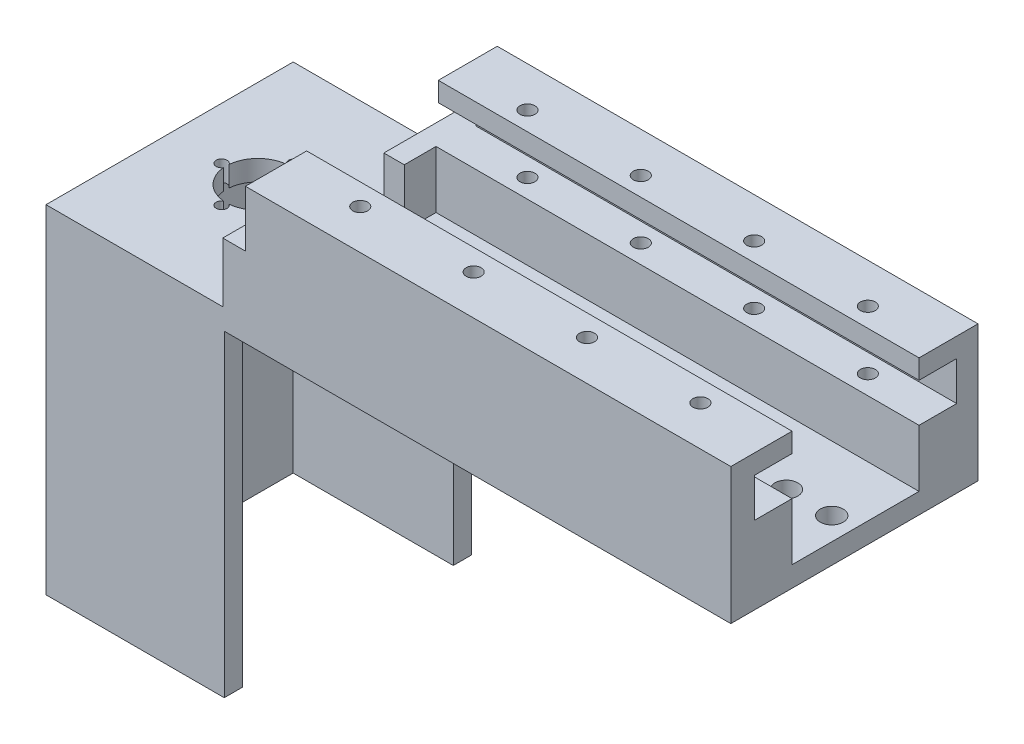
from build123d import *

# Parameters (mm, degrees)
SKETCH4_W                  = 106
SKETCH4_H                  = 30
BOSS_EXTRUDE2_DEPTH        = 13
SKETCH25_W                 = 106
SKETCH25_H                 = 8.6
CUT_EXTRUDE3_DEPTH         = 1
CUT_EXTRUDE3_DEPTH_BACK    = 8.3
M4X0_7_TAPPED_HOLE1_D      = 3.3
SKETCH28_W                 = 106
SKETCH28_H                 = 4.5
BOSS_EXTRUDE3_DEPTH        = 41.5
SKETCH32_W                 = 41.5
SKETCH32_H                 = 4.5
BOSS_EXTRUDE10_DEPTH       = 5
SKETCH33_W                 = 13
SKETCH33_H                 = 17.121445937
BOSS_EXTRUDE12_DEPTH       = 5
SKETCH34_W                 = 4.498886861
SKETCH34_H                 = 12.621445937
BOSS_EXTRUDE13_DEPTH       = 7
SKETCH35_W                 = 54.5
SKETCH35_H                 = 4.5
BOSS_EXTRUDE14_DEPTH       = 40
SKETCH36_W                 = 5
SKETCH36_H                 = 20
BOSS_EXTRUDE15_DEPTH       = 13.12
F_8_0_199_DIAMETER_HOLE1_D = 5.0546
SKETCH39_R                 = 7
CUT_EXTRUDE4_DEPTH         = 10
M2_CLEARANCE_HOLE1_D       = 2.4
SKETCH43_W                 = 35.304815243
SKETCH43_H                 = 4
BOSS_EXTRUDE16_DEPTH       = 70
SKETCH44_W                 = 107.027081708
SKETCH44_H                 = 13.5
BOSS_EXTRUDE17_DEPTH       = 25.5
SKETCH47_W                 = 107.027081708
SKETCH47_H                 = 8.6
CUT_EXTRUDE5_DEPTH         = 8.3
M4X0_7_TAPPED_HOLE2_D      = 3.3


with BuildPart() as part:
    # Sketch4 → Boss-Extrude2 (new body)
    with BuildSketch(Plane.XY):
        with Locations((-36.891047602, -35.322762913)):
            Rectangle(SKETCH4_W, SKETCH4_H)
    extrude(amount=-BOSS_EXTRUDE2_DEPTH)

    # Sketch25 → Cut-Extrude3 (cut, two sides)
    with BuildSketch(Plane.XY) as cut_extrude3_sk:
        with Locations((-36.891047602, -28.901316976)):
            Rectangle(SKETCH25_W, SKETCH25_H)
    extrude(amount=CUT_EXTRUDE3_DEPTH, mode=Mode.SUBTRACT)
    extrude(cut_extrude3_sk.sketch, amount=-CUT_EXTRUDE3_DEPTH_BACK, mode=Mode.SUBTRACT)

    # M4x0.7 Tapped Hole1 (through all)
    with Locations(Plane(origin=(-74.390985602, -20.322762913, -4.15), x_dir=(0, 0, 1), z_dir=(0, 1, 0))):
        with Locations((0, 0), (0, 25), (-0.055677319, 74.999938), (0, 50)):
            Hole(M4X0_7_TAPPED_HOLE1_D / 2)

    # Sketch28 → Boss-Extrude3 (add)
    with BuildSketch(Plane.XY):
        with Locations((-36.891047602, -48.072762913)):
            Rectangle(SKETCH28_W, SKETCH28_H)
    extrude(amount=BOSS_EXTRUDE3_DEPTH)

    # Sketch32 → Boss-Extrude10 (add)
    with BuildSketch(Plane.ZY.offset(89.891047602)):
        with Locations((20.75, -48.072762913)):
            Rectangle(SKETCH32_W, SKETCH32_H)
    extrude(amount=BOSS_EXTRUDE10_DEPTH)

    # Sketch33 → Boss-Extrude12 (add)
    with BuildSketch(Plane.ZY.offset(89.891047602)):
        with Locations((-6.5, -41.762039945)):
            Rectangle(SKETCH33_W, SKETCH33_H)
    extrude(amount=BOSS_EXTRUDE12_DEPTH)

    # Sketch34 → Boss-Extrude13 (add)
    with BuildSketch(Plane.XY):
        with Locations((-92.641604172, -39.512039945)):
            Rectangle(SKETCH34_W, SKETCH34_H)
    extrude(amount=BOSS_EXTRUDE13_DEPTH)

    # Sketch35 → Boss-Extrude14 (add)
    with BuildSketch(Plane.ZY.offset(94.891047602)):
        with Locations((14.25, -48.072762913)):
            Rectangle(SKETCH35_W, SKETCH35_H)
    extrude(amount=BOSS_EXTRUDE14_DEPTH)

    # Sketch36 → Boss-Extrude15 (add)
    with BuildSketch(Plane(origin=(0, -45.822762913, 0), x_dir=(1, 0, 0), z_dir=(0, 1, 0))):
        with Locations((-93.41812931, -31.5)):
            Rectangle(SKETCH36_W, SKETCH36_H)
    extrude(amount=BOSS_EXTRUDE15_DEPTH)

    # #8 (0.199) Diameter Hole1 (through all)
    with Locations(Plane(origin=(-80.669073904, -45.822762913, 14.25), x_dir=(0, 0, 1), z_dir=(0, 1, 0))):
        with Locations((0, 0), (0, 91.778026302), (0, 81.778026302), (0, 10)):
            Hole(F_8_0_199_DIAMETER_HOLE1_D / 2)

    # Sketch39 → Cut-Extrude4 (cut)
    with BuildSketch(Plane(origin=(0, -45.822762913, 0), x_dir=(1, 0, 0), z_dir=(0, 1, 0))):
        with Locations((-115.41812931, -14.25)):
            Circle(SKETCH39_R)
    extrude(amount=-CUT_EXTRUDE4_DEPTH, mode=Mode.SUBTRACT)

    # M2 Clearance Hole1 (through all)
    with Locations(Plane(origin=(-107.41812931, -45.822762913, 14.25), x_dir=(0, 0, 1), z_dir=(0, 1, 0))):
        with Locations((0, 0), (8.000007036, -8.002918292), (-7.999992964, -8.002918292), (0, -16)):
            Hole(M2_CLEARANCE_HOLE1_D / 2)

    # Sketch43 → Boss-Extrude16 (add)
    with BuildSketch(Plane(origin=(0, -50.322762913, 0), x_dir=(-1, 0, 0), z_dir=(0, -1, 0))):
        Polygon((95.586232359, -37.5), (95.586232359, -41.5), (134.891047602, -41.5), (134.891047602, -37.5), (130.891047602, -37.5), align=None)
        Polygon((130.891047602, -37.5), (134.891047602, -37.5), (134.891047602, 13), (130.891047602, 13), (130.891047602, 9), align=None)
        with Locations((113.238639981, 11)):
            Rectangle(SKETCH43_W, SKETCH43_H)
    extrude(amount=BOSS_EXTRUDE16_DEPTH)

    # Sketch44 → Boss-Extrude17 (add)
    with BuildSketch(Plane(origin=(0, -45.822762913, 0), x_dir=(1, 0, 0), z_dir=(0, 1, 0))):
        with Locations((-37.404588456, -34.75)):
            Rectangle(SKETCH44_W, SKETCH44_H)
    extrude(amount=BOSS_EXTRUDE17_DEPTH)

    # Sketch47 → Cut-Extrude5 (cut)
    with BuildSketch(Plane(origin=(0, 0, 28), x_dir=(-1, 0, 0), z_dir=(0, 0, -1))):
        with Locations((37.404588456, -28.902762913)):
            Rectangle(SKETCH47_W, SKETCH47_H)
    extrude(amount=-CUT_EXTRUDE5_DEPTH, mode=Mode.SUBTRACT)

    # M4x0.7 Tapped Hole2 (through all)
    with Locations(Plane(origin=(-74.391047602, -20.322762913, 32.71), x_dir=(0, 0, 1), z_dir=(0, 1, 0))):
        with Locations((0, 0), (0, 25), (0, 50), (0, 75)):
            Hole(M4X0_7_TAPPED_HOLE2_D / 2)


solid = part.part
